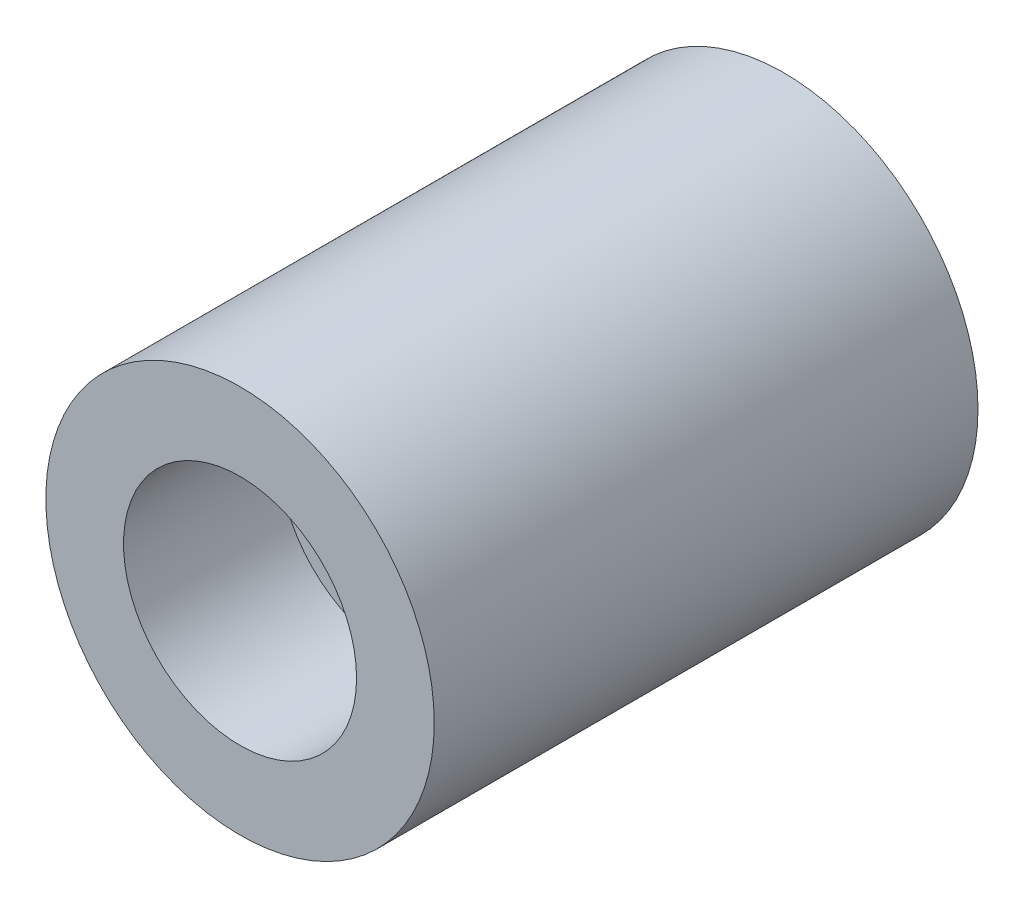
from build123d import *

# Parameters (mm, degrees)
SKETCH1_R           = 50
BOSS_EXTRUDE1_DEPTH = 140
SKETCH2_R           = 10
CUT_EXTRUDE1_DEPTH  = 120
SKETCH3_R           = 30
CUT_EXTRUDE2_DEPTH  = 40


with BuildPart() as part:
    # Sketch1 → Boss-Extrude1 (new body)
    with BuildSketch(Plane.XY):
        Circle(SKETCH1_R)
    extrude(amount=BOSS_EXTRUDE1_DEPTH)

    # Sketch2 → Cut-Extrude1 (cut)
    with BuildSketch(Plane.XY.offset(140)):
        Circle(SKETCH2_R)
    extrude(amount=-CUT_EXTRUDE1_DEPTH, mode=Mode.SUBTRACT)

    # Sketch3 → Cut-Extrude2 (cut)
    with BuildSketch(Plane.XY.offset(140)):
        Circle(SKETCH3_R)
    extrude(amount=-CUT_EXTRUDE2_DEPTH, mode=Mode.SUBTRACT)


solid = part.part
